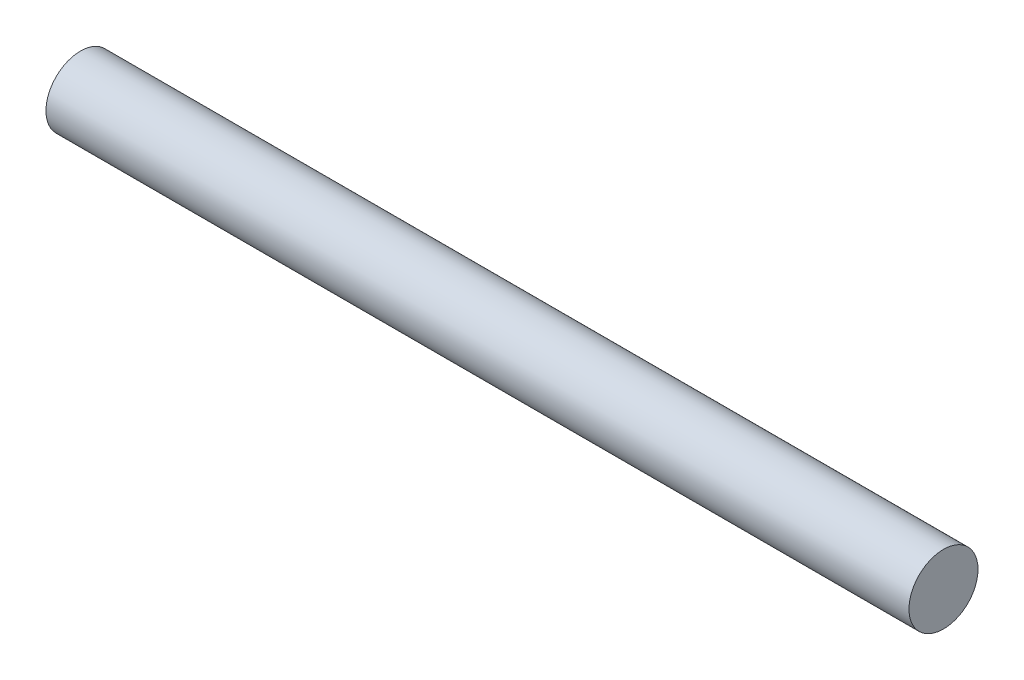
from build123d import *

# Parameters (mm, degrees)
SKETCH1_R           = 4
BOSS_EXTRUDE1_DEPTH = 100


with BuildPart() as part:
    # Sketch1 → Boss-Extrude1 (new body)
    with BuildSketch(Plane(origin=(0, 0, 0), x_dir=(0, 0, -1), z_dir=(1, 0, 0))):
        Circle(SKETCH1_R)
    extrude(amount=BOSS_EXTRUDE1_DEPTH)


solid = part.part
